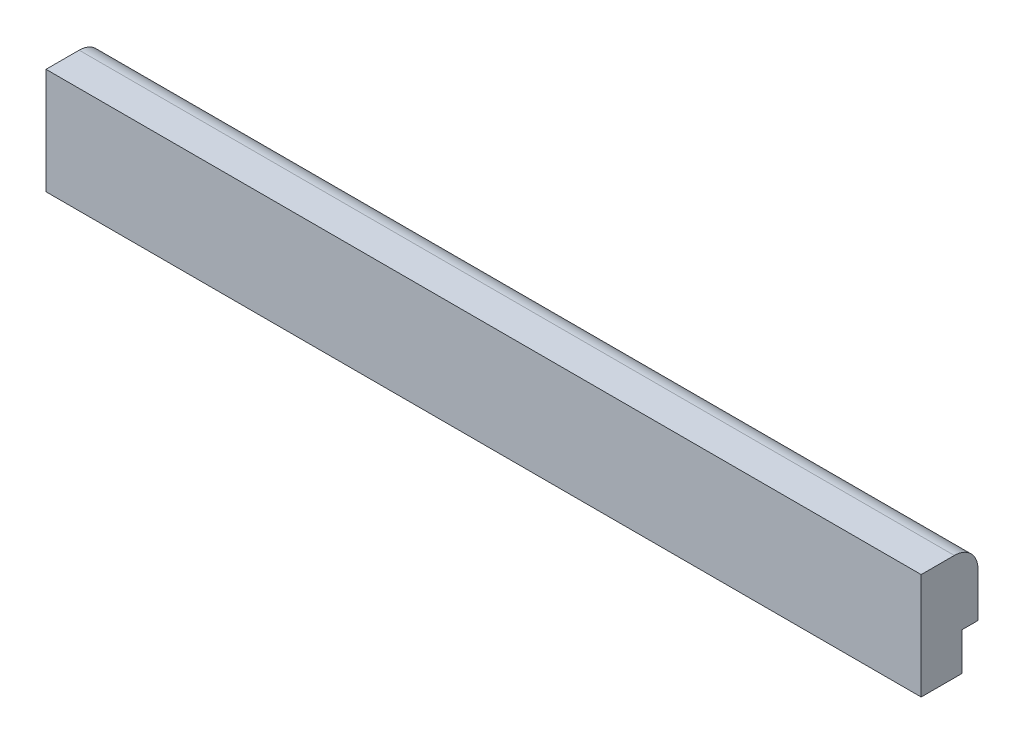
from build123d import *

# Parameters (mm, degrees)
ESQUISSE1_W             = 462
ESQUISSE1_H             = 56
BOSS_EXTRU_1_DEPTH      = 21.5
BOSS_EXTRU_1_DEPTH_BACK = 8.5
ENL_V_START             = -8.5
ESQUISSE2_W             = 462
ESQUISSE2_H             = 20
ENL_V_MAT_EXTRU_2_DEPTH = 8.5
CONG_1_R                = 12.5


with BuildPart() as part:
    # Esquisse1 → Boss.-Extru.1 (new body, two sides)
    with BuildSketch(Plane.XY) as boss_extru_1_sk:
        with Locations((30, 8)):
            Rectangle(ESQUISSE1_W, ESQUISSE1_H)
    extrude(amount=BOSS_EXTRU_1_DEPTH)
    extrude(boss_extru_1_sk.sketch, amount=-BOSS_EXTRU_1_DEPTH_BACK)

    # Esquisse2 → Enl_v. mat.-Extru.2 (cut)
    with BuildSketch(Plane(origin=(0, 0, -8.5), x_dir=(-1, 0, 0), z_dir=(0, 0, -1)).offset(ENL_V_START)):
        with Locations((-30, -10)):
            Rectangle(ESQUISSE2_W, ESQUISSE2_H)
    extrude(amount=ENL_V_MAT_EXTRU_2_DEPTH, mode=Mode.SUBTRACT)

    # Cong_1
    cong_1_edges = [part.edges().sort_by_distance(p)[0] for p in [
        (30, 36, -8.5),
    ]]
    fillet(cong_1_edges, radius=CONG_1_R)


solid = part.part
